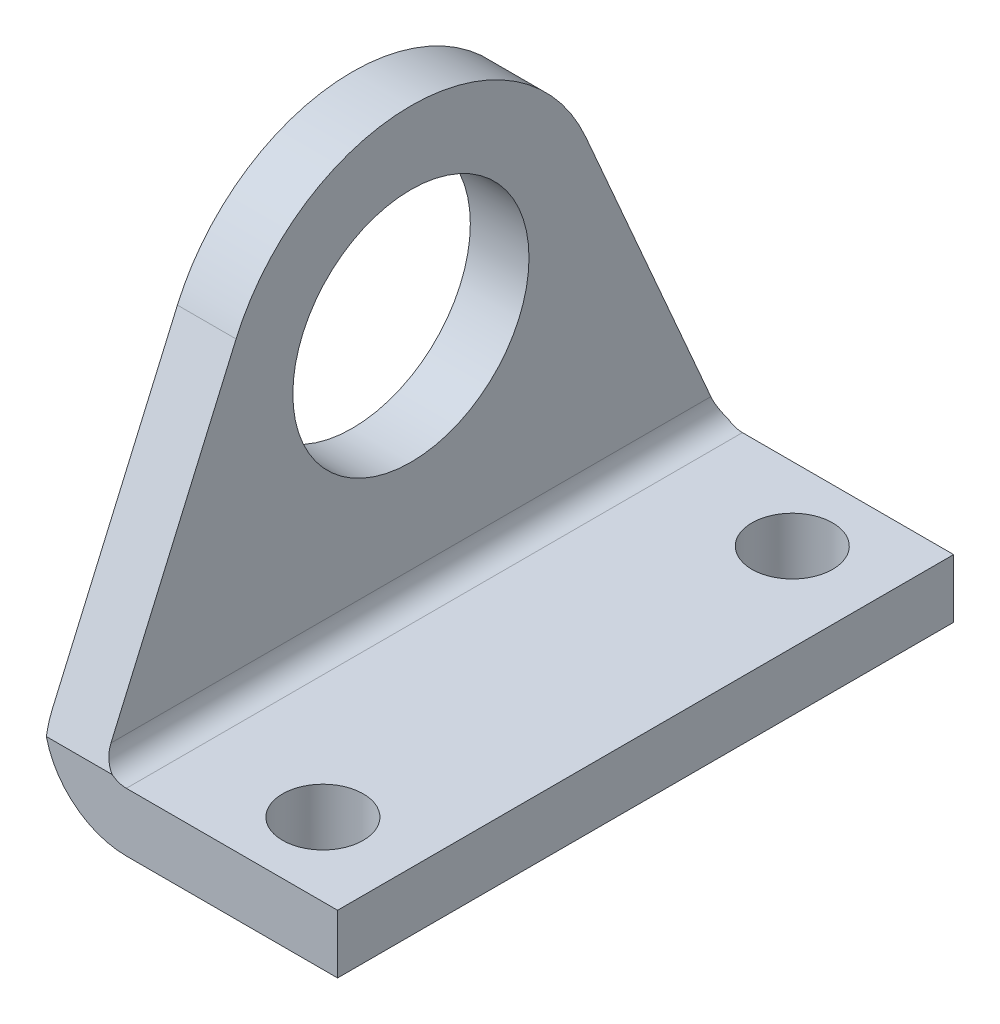
from build123d import *

# Parameters (mm, degrees)
EXTRUSION1_DEPTH      = 21
EXTRUSION1_DEPTH_BACK = 21
EXTRUSION2_DEPTH      = 14
SKIZZE3_R             = 8.05
EXTRUSION3_DEPTH      = 4.1
SKIZZE4_R             = 2.75
EXTRUSION4_DEPTH      = 4.1
SKIZZE5_R             = 2.75
EXTRUSION5_DEPTH      = 4.1


with BuildPart() as part:
    # Skizze1 → Extrusion1 (new body, two sides)
    with BuildSketch(Plane.XY) as extrusion1_sk:
        with BuildLine():
            Line((0, 40), (0, 5.6))
            ThreePointArc((0, 5.6), (1.640202025, 1.640202025), (5.6, 0))
            Line((5.6, 0), (20, 0))
            Line((20, 0), (20, 4))
            Line((20, 4), (5.6, 4))
            ThreePointArc((5.6, 4), (4.46862915, 4.46862915), (4, 5.6))
            Line((4, 5.6), (4, 40))
            Line((4, 40), (0, 40))
        make_face()
    extrude(amount=EXTRUSION1_DEPTH)
    extrude(extrusion1_sk.sketch, amount=-EXTRUSION1_DEPTH_BACK)

    # Skizze2 → Extrusion2 (cut, symmetric)
    with BuildSketch(Plane.YZ):
        with BuildLine():
            Line((64.1, 63.1), (-1, 63.1))
            Line((-1, 63.1), (-1, 23.320142873))
            Line((-1, 23.320142873), (25.188847397, 11.919557991))
            ThreePointArc((25.188847397, 11.919557991), (33, 0), (25.188847397, -11.919557991))
            Line((25.188847397, -11.919557991), (-1, -23.320142873))
            Line((-1, -23.320142873), (-1, -63.1))
            Line((-1, -63.1), (64.1, -63.1))
            Line((64.1, -63.1), (64.1, 63.1))
        make_face()
    extrude(amount=EXTRUSION2_DEPTH, both=True, mode=Mode.SUBTRACT)

    # Skizze3 → Extrusion3 (cut, symmetric)
    with BuildSketch(Plane.YZ):
        with Locations(Location((20, 0, 0), (0, 0, 90))):  # turned: the seam where the file's is
            Circle(SKIZZE3_R)
    extrude(amount=EXTRUSION3_DEPTH, both=True, mode=Mode.SUBTRACT)

    # Skizze4 → Extrusion4 (cut, symmetric)
    with BuildSketch(Plane(origin=(0, 0, 0), x_dir=(-1, 0, 0), z_dir=(0, 1, 0))):
        with Locations(Location((-14, -16, 0), (0, 0, 180))):  # turned: the seam where the file's is
            Circle(SKIZZE4_R)
    extrude(amount=EXTRUSION4_DEPTH, both=True, mode=Mode.SUBTRACT)

    # Skizze5 → Extrusion5 (cut, symmetric)
    with BuildSketch(Plane(origin=(0, 0, 0), x_dir=(-1, 0, 0), z_dir=(0, 1, 0))):
        with Locations(Location((-14, 16, 0), (0, 0, 180))):  # turned: the seam where the file's is
            Circle(SKIZZE5_R)
    extrude(amount=EXTRUSION5_DEPTH, both=True, mode=Mode.SUBTRACT)


solid = part.part
